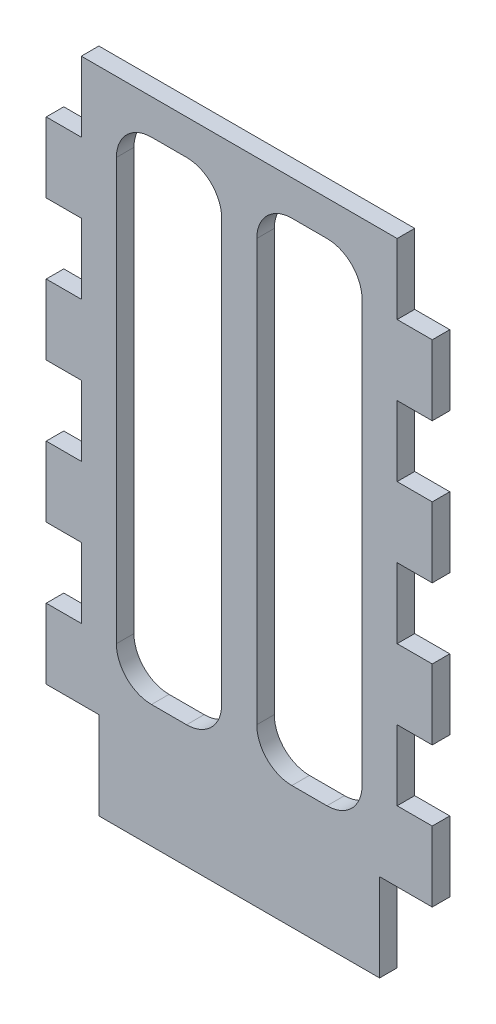
from build123d import *

# Parameters (mm, degrees)
SKETCH1_W           = 57.15
SKETCH1_H           = 101.6
BOSS_EXTRUDE1_DEPTH = 3.175
SKETCH2_W           = 6.35
SKETCH2_H           = 12.7
BOSS_EXTRUDE2_DEPTH = 3.175
LPATTERN1_COUNT     = 4
LPATTERN1_PITCH     = 25.4
SKETCH3_W           = 50.8
SKETCH3_H           = 15.875
BOSS_EXTRUDE3_DEPTH = 3.175
SKETCH4_W           = 19.05
SKETCH4_H           = 88.9
CUT_EXTRUDE1_DEPTH  = 3.175
FILLET1_R           = 6.35


with BuildPart() as part:
    # Sketch1 → Boss-Extrude1 (new body)
    with BuildSketch(Plane.XY):
        with Locations((28.575, -50.8)):
            Rectangle(SKETCH1_W, SKETCH1_H)
    extrude(amount=BOSS_EXTRUDE1_DEPTH)

    # Sketch2 → Boss-Extrude2 (add)
    with BuildSketch(Plane.XY.offset(3.175)):
        with Locations((60.325, -19.05)):
            Rectangle(SKETCH2_W, SKETCH2_H)
        with Locations((-3.175, -19.05)):
            Rectangle(SKETCH2_W, SKETCH2_H)
    boss_extrude2 = extrude(amount=-BOSS_EXTRUDE2_DEPTH)

    # LPattern1: Boss-Extrude2 ×4
    with Locations(*[(0, -i * LPATTERN1_PITCH, 0) for i in range(1, LPATTERN1_COUNT)]):
        add(boss_extrude2)

    # Sketch3 → Boss-Extrude3 (add)
    with BuildSketch(Plane.XY.offset(3.175)):
        with Locations((28.575, -109.5375)):
            Rectangle(SKETCH3_W, SKETCH3_H)
    extrude(amount=-BOSS_EXTRUDE3_DEPTH)

    # Sketch4 → Cut-Extrude1 (cut)
    with BuildSketch(Plane.XY.offset(3.175)):
        with Locations((15.875, -50.8)):
            Rectangle(SKETCH4_W, SKETCH4_H)
        with Locations((41.275, -50.8)):
            Rectangle(SKETCH4_W, SKETCH4_H)
    extrude(amount=-CUT_EXTRUDE1_DEPTH, mode=Mode.SUBTRACT)

    # Fillet1
    fillet1_edges = [part.edges().sort_by_distance(p)[0] for p in [
        (6.35, -95.25, 1.5875),
        (6.35, -6.35, 1.5875),
        (25.4, -6.35, 1.5875),
        (25.4, -95.25, 1.5875),
        (50.8, -6.35, 1.5875),
        (50.8, -95.25, 1.5875),
        (31.75, -95.25, 1.5875),
        (31.75, -6.35, 1.5875),
    ]]
    fillet(fillet1_edges, radius=FILLET1_R)


solid = part.part
